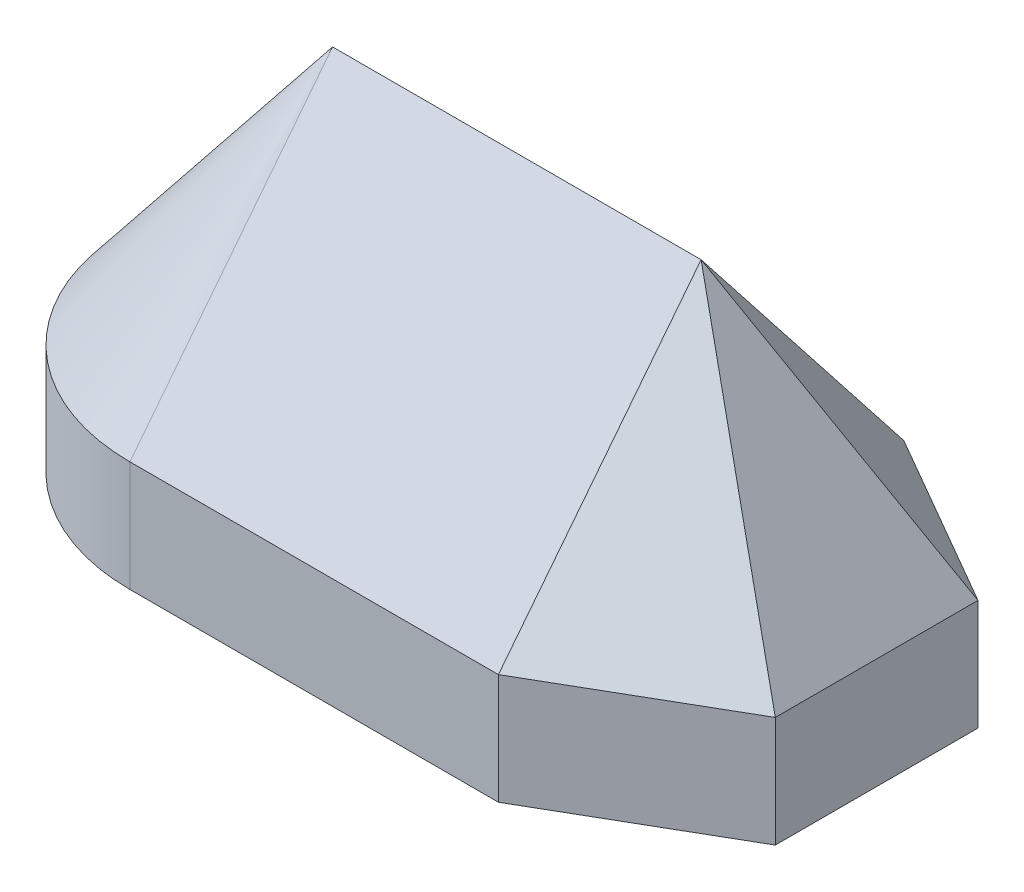
from build123d import *

# Parameters (mm, degrees)
EXTRUDE1_DEPTH = 12
EXTRUDE2_DEPTH = 40
REVOLVE1_ANGLE = 180


with BuildPart() as part:
    # Sketch1 → Extrude1 (new body)
    with BuildSketch(Plane(origin=(0, 0, 0), x_dir=(1, 0, 0), z_dir=(0, 1, 0))):
        with BuildLine():
            Line((0, -22), (40, -22))
            Line((40, -22), (59.052558883, -11))
            Line((59.052558883, -11), (59.052558883, 11))
            Line((59.052558883, 11), (40, 22))
            Line((40, 22), (0, 22))
            ThreePointArc((0, 22), (-22, 0), (0, -22))
        make_face()
    extrude(amount=EXTRUDE1_DEPTH)

    # Sketch2 → Extrude2 (add)
    with BuildSketch(Plane(origin=(0, 0, 0), x_dir=(0, 0, -1), z_dir=(1, 0, 0))):
        Polygon((0, 40), (-22, 12), (22, 12), align=None)
    extrude(amount=EXTRUDE2_DEPTH)

    # Sketch3 → Revolve1 (revolve)
    with BuildSketch(Plane.ZY):
        Polygon((0, 40), (0, 12), (22, 12), align=None)
    revolve(axis=Axis((0, 40, 0), (0, -1, 0)), revolution_arc=REVOLVE1_ANGLE)

    # Sketch4 → Loft1 section 0
    with BuildSketch(Plane(origin=(0, 12, 0), x_dir=(-1, 0, 0), z_dir=(0, 1, 0)), mode=Mode.PRIVATE) as loft1_s0:
        Polygon((-59.052558883, 11), (-59.052558883, -11), (-40, -22), (-40, 22), align=None)
    loft([Vertex(40, 40, 0), loft1_s0.sketch])


solid = part.part
